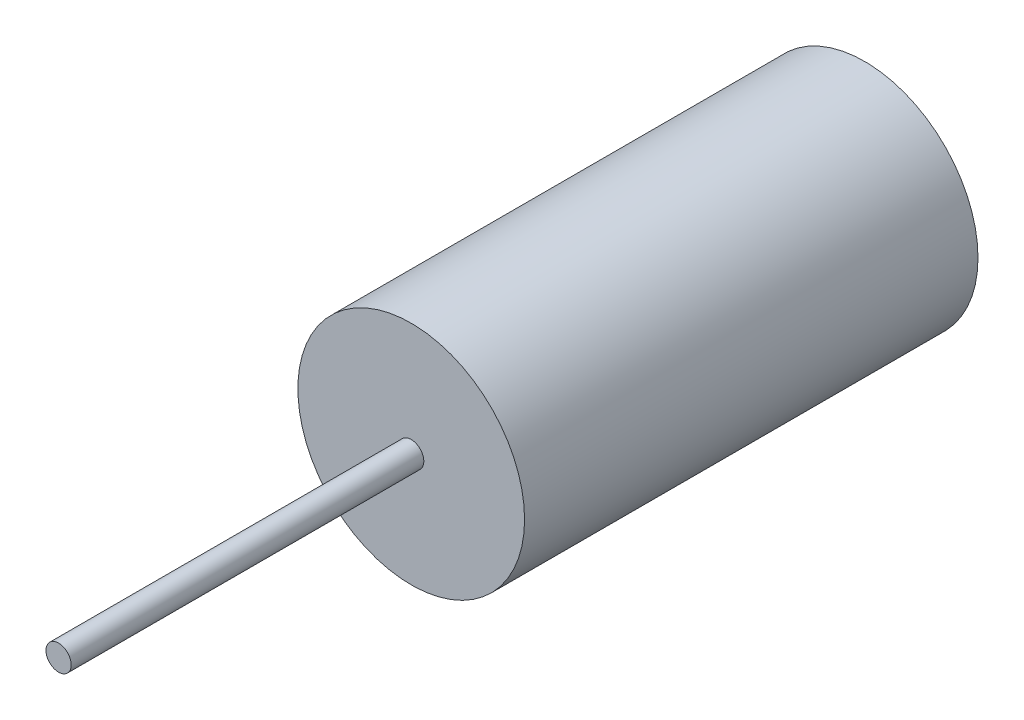
from build123d import *

# Parameters (mm, degrees)
SKETCH1_R           = 57.15
BOSS_EXTRUDE1_DEPTH = 228.6
SKETCH2_R           = 6.35
BOSS_EXTRUDE2_DEPTH = 177.8


with BuildPart() as part:
    # Sketch1 → Boss-Extrude1 (new body)
    with BuildSketch(Plane.XY):
        Circle(SKETCH1_R)
    extrude(amount=BOSS_EXTRUDE1_DEPTH)

    # Sketch2 → Boss-Extrude2 (add)
    with BuildSketch(Plane.XY.offset(228.6)):
        Circle(SKETCH2_R)
    extrude(amount=BOSS_EXTRUDE2_DEPTH)


solid = part.part
